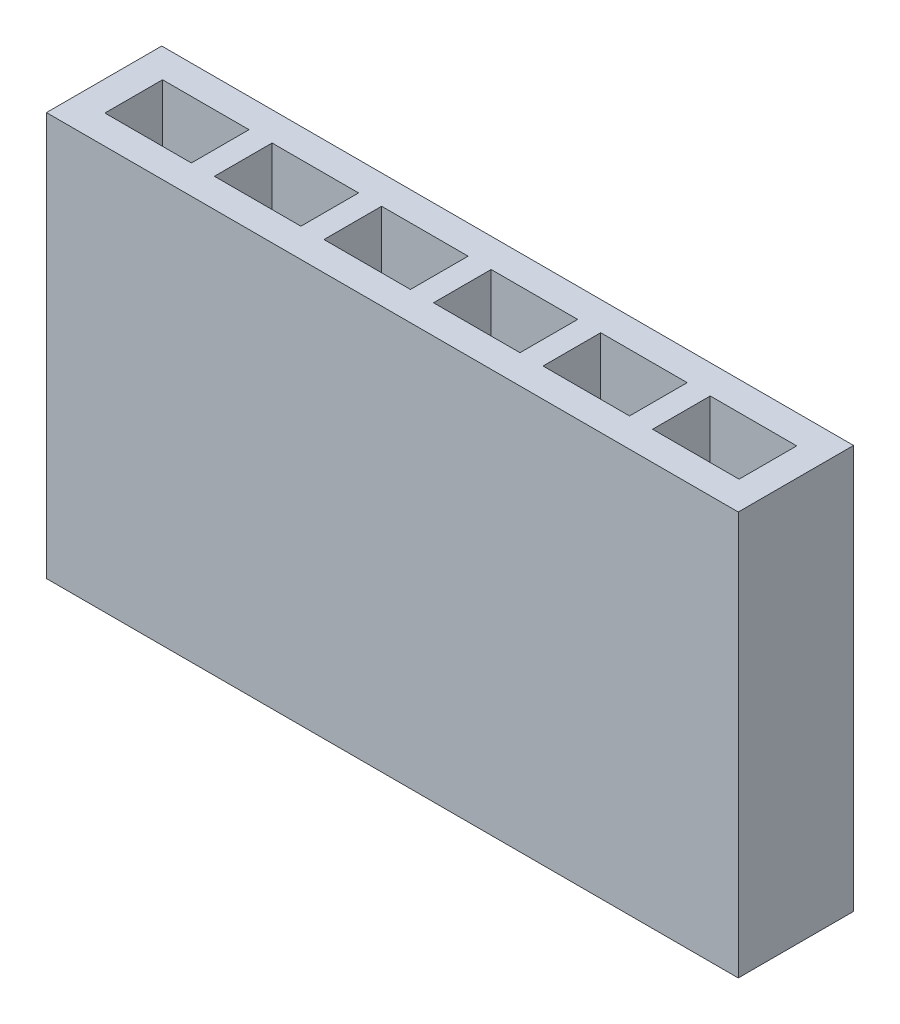
from build123d import *

# Parameters (mm, degrees)
SKETCH1_W           = 12
SKETCH1_H           = 7
BOSS_EXTRUDE1_DEPTH = 2
SKETCH3_W           = 1.5
SKETCH3_H           = 1
CUT_EXTRUDE1_DEPTH  = 4
LPATTERN1_COUNT     = 6
LPATTERN1_PITCH     = 1.9


with BuildPart() as part:
    # Sketch1 → Boss-Extrude1 (new body)
    with BuildSketch(Plane.XY):
        with Locations((6, 3.5)):
            Rectangle(SKETCH1_W, SKETCH1_H)
    extrude(amount=BOSS_EXTRUDE1_DEPTH)

    # Sketch3 → Cut-Extrude1 (cut)
    with BuildSketch(Plane(origin=(0, 7, 0), x_dir=(1, 0, 0), z_dir=(0, 1, 0))):
        with Locations((1.263938608, -1)):
            Rectangle(SKETCH3_W, SKETCH3_H)
    cut_extrude1 = extrude(amount=-CUT_EXTRUDE1_DEPTH, mode=Mode.SUBTRACT)

    # LPattern1: Cut-Extrude1 ×6
    with Locations(*[(i * LPATTERN1_PITCH, 0, 0) for i in range(1, LPATTERN1_COUNT)]):
        add(cut_extrude1, mode=Mode.SUBTRACT)


solid = part.part
